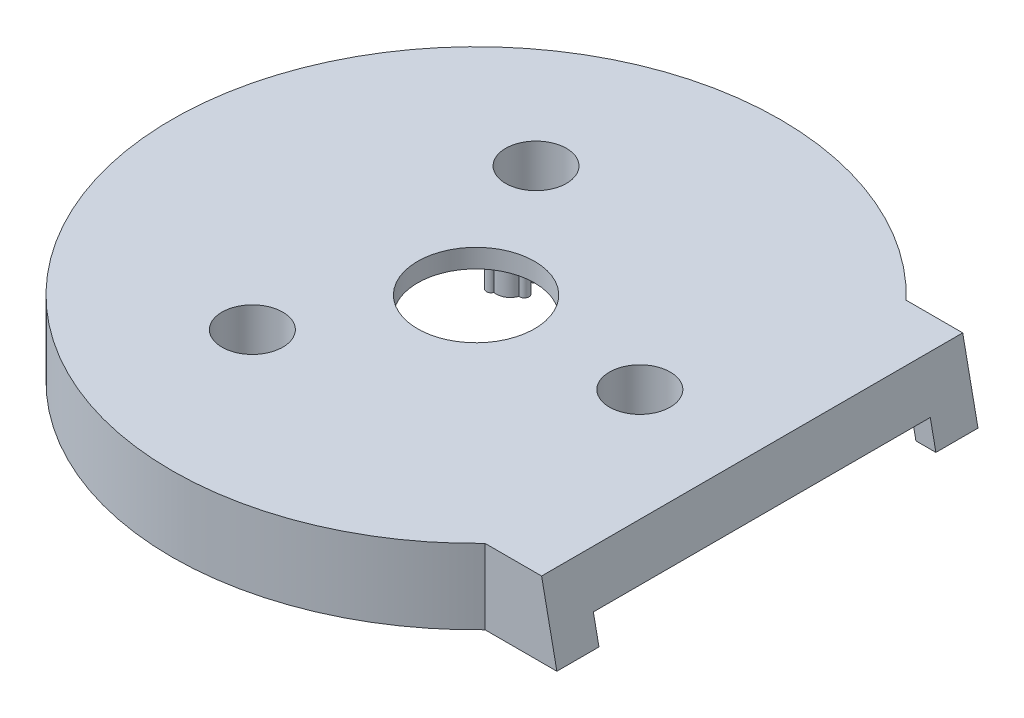
from build123d import *

# Parameters (mm, degrees)
BOSS_EXTRUDE1_DEPTH         = 16
CUT_EXTRUDE1_DEPTH          = 12
SKETCH4_W                   = 72
SKETCH4_H                   = 5
CUT_EXTRUDE2_DEPTH          = 16
SKETCH8_R                   = 3.5
SKETCH8_R_2                 = 1.5
INTERNALHOLESBODY_DEPTH     = 12
SKETCH13_R                  = 1.5
INTERNALHOLESCUT_DEPTH      = 12
SKETCH15_W                  = 14.23560612
SKETCH15_H                  = 16
INTERNALBODYEXTENSION_DEPTH = 90
EXTERNALDIAGONALCUT_DEPTH   = 90
DIAGONALCUT_START           = -4.8
DIAGONALCUT_DEPTH           = 80.4
SKETCH19_W                  = 72
SKETCH19_H                  = 6
DISPLAYCUT_DEPTH            = 8.4
SKETCH26_R                  = 6.5
BOSS_EXTRUDE2_DEPTH         = 11
SKETCH27_R                  = 6.5
CUT_EXTRUDE3_DEPTH          = 5
SKETCH28_R                  = 8
BOSS_EXTRUDE3_DEPTH         = 1
BOSS_EXTRUDE3_DEPTH_BACK    = 2
SKETCH30_R                  = 1.5
CUT_EXTRUDE4_DEPTH          = 3
SKETCH31_R                  = 8
SKETCH31_R_2                = 1.5
BOSS_EXTRUDE4_DEPTH         = 1
BOSS_EXTRUDE4_DEPTH_BACK    = 2
SKETCH32_R                  = 8
SKETCH32_R_2                = 1.5
BOSS_EXTRUDE5_DEPTH         = 1
BOSS_EXTRUDE5_DEPTH_BACK    = 2
SKETCH34_R                  = 1.5
BOSS_EXTRUDE6_DEPTH         = 8
SKETCH33_R                  = 12.5
CUT_EXTRUDE5_DEPTH          = 5
SKETCH35_R                  = 2
BOSS_EXTRUDE7_DEPTH         = 3


with BuildPart() as part:
    # Sketch1 → Boss-Extrude1 (new body)
    with BuildSketch(Plane(origin=(0, 0, 0), x_dir=(1, 0, 0), z_dir=(0, 1, 0))):
        with BuildLine():
            Line((25, -45.0001724), (25, 44.9998276))
            Line((25, 44.9998276), (46.904322999, 44.9998276))
            ThreePointArc((46.904322999, 44.9998276), (-65, 0.000238913), (46.903992196, -45.0001724))
            Line((46.903992196, -45.0001724), (25, -45.0001724))
        make_face()
        with BuildLine():
            Line((46.904322999, 44.9998276), (25, 44.9998276))
            Line((25, 44.9998276), (25, -45.0001724))
            Line((25, -45.0001724), (46.903992196, -45.0001724))
            ThreePointArc((46.903992196, -45.0001724), (60.306548122, -24.251190767), (65, 0))
            ThreePointArc((65, 0), (60.306637259, 24.250969105), (46.904322999, 44.9998276))
        make_face()
        with BuildLine():
            Line((69, 44.9998276), (46.904322999, 44.9998276))
            ThreePointArc((46.904322999, 44.9998276), (60.306637259, 24.250969105), (65, 0))
            ThreePointArc((65, 0), (60.306548122, -24.251190767), (46.903992196, -45.0001724))
            Line((46.903992196, -45.0001724), (69, -45.0001724))
            Line((69, -45.0001724), (69, 44.9998276))
        make_face()
    extrude(amount=BOSS_EXTRUDE1_DEPTH)

    # Sketch3 → Cut-Extrude1 (cut)
    with BuildSketch(Plane.XZ):
        with BuildLine():
            Line((13.648760289, 40.2001724), (44.541510291, 40.2001724))
            ThreePointArc((44.541510291, 40.2001724), (-60, -0.000232232), (44.541821482, -40.1998276))
            Line((44.541821482, -40.1998276), (13.648760289, -40.1998276))
            Line((13.648760289, -40.1998276), (13.648760289, 40.2001724))
        make_face()
        with BuildLine():
            ThreePointArc((60, 0), (56.002190214, 21.53496439), (44.541510291, 40.2001724))
            Line((44.541510291, 40.2001724), (13.648760289, 40.2001724))
            Line((13.648760289, 40.2001724), (13.648760289, -40.1998276))
            Line((13.648760289, -40.1998276), (44.541821482, -40.1998276))
            ThreePointArc((44.541821482, -40.1998276), (56.002273565, -21.534747631), (60, 0))
        make_face()
        with BuildLine():
            Line((64, -40.1998276), (64, 40.2001724))
            Line((64, 40.2001724), (44.541510291, 40.2001724))
            ThreePointArc((44.541510291, 40.2001724), (56.002190214, 21.53496439), (60, 0))
            ThreePointArc((60, 0), (56.002273565, -21.534747631), (44.541821482, -40.1998276))
            Line((44.541821482, -40.1998276), (64, -40.1998276))
        make_face()
    extrude(amount=-CUT_EXTRUDE1_DEPTH, mode=Mode.SUBTRACT)

    # Sketch4 → Cut-Extrude2 (cut)
    with BuildSketch(Plane(origin=(69, 0, 0), x_dir=(0, 0, -1), z_dir=(1, 0, 0))):
        with Locations((-0.0001724, 2.5)):
            Rectangle(SKETCH4_W, SKETCH4_H)
    extrude(amount=-CUT_EXTRUDE2_DEPTH, mode=Mode.SUBTRACT)

    # Sketch8 → InternalHolesBody (add)
    with BuildSketch(Plane.XZ.offset(-12)):
        with Locations((-25.212285918, 54.445758685)):
            Circle(SKETCH8_R)
        with Locations((-25.212285918, 54.445758685)):
            Circle(SKETCH8_R_2, mode=Mode.SUBTRACT)
        with Locations((-25, -54.543560573)):
            Circle(SKETCH8_R)
        with Locations((-25, -54.543560573)):
            Circle(SKETCH8_R_2, mode=Mode.SUBTRACT)
        with Locations((44.541510291, 40.2001724)):
            Circle(SKETCH8_R)
        with Locations((44.541510291, 40.2001724)):
            Circle(SKETCH8_R_2, mode=Mode.SUBTRACT)
        with Locations((44.541821482, -40.1998276)):
            Circle(SKETCH8_R)
        with Locations((44.541821482, -40.1998276)):
            Circle(SKETCH8_R_2, mode=Mode.SUBTRACT)
    extrude(amount=INTERNALHOLESBODY_DEPTH)

    # Sketch13 → InternalHolesCut (cut)
    with BuildSketch(Plane.XZ.offset(-12)):
        with Locations((44.541510291, 40.2001724)):
            Circle(SKETCH13_R)
        with Locations((-25.212285918, 54.445758685)):
            Circle(SKETCH13_R)
        with Locations((-25, -54.543560573)):
            Circle(SKETCH13_R)
        with Locations((44.541821482, -40.1998276)):
            Circle(SKETCH13_R)
    extrude(amount=INTERNALHOLESCUT_DEPTH, mode=Mode.SUBTRACT)

    # Sketch15 → InternalBodyExtension (add)
    with BuildSketch(Plane.XY.offset(45.0001724)):
        with Locations((61.88219694, 8)):
            Rectangle(SKETCH15_W, SKETCH15_H)
    extrude(amount=-INTERNALBODYEXTENSION_DEPTH)

    # Sketch14 → ExternalDiagonalCut (cut)
    with BuildSketch(Plane(origin=(0, 0, -44.9998276), x_dir=(-1, 0, 0), z_dir=(0, 0, -1))):
        Polygon((-69, 16), (-59, 16), (-69, -33), align=None)
    extrude(amount=-EXTERNALDIAGONALCUT_DEPTH, mode=Mode.SUBTRACT)

    # Sketch17 → DiagonalCut (cut)
    with BuildSketch(Plane.XY.offset(45.0001724).offset(DIAGONALCUT_START)):
        Polygon((58.000000002, 0), (54.73469388, 0), (54.73469388, 12), (55.551020411, 12), align=None)
    extrude(amount=-DIAGONALCUT_DEPTH, mode=Mode.SUBTRACT)

    # Sketch19 → DisplayCut (cut)
    with BuildSketch(Plane(origin=(59.775689724, 12.199120352, 0), x_dir=(0, 0, -1), z_dir=(0.979804059, 0.199960012, 0))):
        with Locations((-0.0001724, -9.450571359)):
            Rectangle(SKETCH19_W, SKETCH19_H)
    extrude(amount=-DISPLAYCUT_DEPTH, mode=Mode.SUBTRACT)

    # Sketch26 → Boss-Extrude2 (add)
    with BuildSketch(Plane.XZ.offset(-12)):
        with BuildLine():
            ThreePointArc((-20.136370657, 22.757773897), (-13.5, 23.382685902), (-9.640625, 28.817495477))
            ThreePointArc((-9.640625, 28.817495477), (-8, 30.310889132), (-9.640625, 31.804282788))
            ThreePointArc((-9.640625, 31.804282788), (-13.5, 37.239092363), (-20.136370657, 37.864004368))
            ThreePointArc((-20.136370657, 37.864004368), (-22.25, 38.538130468), (-22.723004343, 36.370610713))
            ThreePointArc((-22.723004343, 36.370610713), (-25.5, 30.310889132), (-22.723004343, 24.251167552))
            ThreePointArc((-22.723004343, 24.251167552), (-22.25, 22.083647797), (-20.136370657, 22.757773897))
        make_face()
        with Locations((-17.5, 30.310889132)):
            Circle(SKETCH26_R, mode=Mode.SUBTRACT)
        with BuildLine():
            ThreePointArc((-22.723004343, -24.251167552), (-25.5, -30.310889132), (-22.723004343, -36.370610713))
            ThreePointArc((-22.723004343, -36.370610713), (-22.25, -38.538130468), (-20.136370657, -37.864004368))
            ThreePointArc((-20.136370657, -37.864004368), (-13.5, -37.239092363), (-9.640625, -31.804282788))
            ThreePointArc((-9.640625, -31.804282788), (-8, -30.310889132), (-9.640625, -28.817495477))
            ThreePointArc((-9.640625, -28.817495477), (-13.5, -23.382685902), (-20.136370657, -22.757773897))
            ThreePointArc((-20.136370657, -22.757773897), (-22.25, -22.083647797), (-22.723004343, -24.251167552))
        make_face()
        with Locations((-17.5, -30.310889132)):
            Circle(SKETCH26_R, mode=Mode.SUBTRACT)
        with BuildLine():
            ThreePointArc((42.859375, 1.493393655), (39, 6.92820323), (32.363629343, 7.553115235))
            ThreePointArc((32.363629343, 7.553115235), (30.25, 8.227241336), (29.776995657, 6.05972158))
            ThreePointArc((29.776995657, 6.05972158), (27, 0), (29.776995657, -6.05972158))
            ThreePointArc((29.776995657, -6.05972158), (30.25, -8.227241336), (32.363629343, -7.553115235))
            ThreePointArc((32.363629343, -7.553115235), (39, -6.92820323), (42.859375, -1.493393655))
            ThreePointArc((42.859375, -1.493393655), (44.5, 0), (42.859375, 1.493393655))
        make_face()
        with Locations((35, 0)):
            Circle(SKETCH26_R, mode=Mode.SUBTRACT)
    extrude(amount=BOSS_EXTRUDE2_DEPTH)

    # Sketch27 → Cut-Extrude3 (cut, through all)
    with BuildSketch(Plane.XZ.offset(-12)):
        with Locations((-17.5, 30.310889132)):
            Circle(SKETCH27_R)
        with Locations((35, 0)):
            Circle(SKETCH27_R)
        with Locations((-17.5, -30.310889132)):
            Circle(SKETCH27_R)
    extrude(amount=-CUT_EXTRUDE3_DEPTH, mode=Mode.SUBTRACT)

    # Sketch28 → Boss-Extrude3 (add, two sides)
    with BuildSketch(Plane.XZ.offset(-1)) as boss_extrude3_sk:
        with Locations((-17.5, 30.310889132)):
            Circle(SKETCH28_R)
    extrude(amount=BOSS_EXTRUDE3_DEPTH)
    extrude(boss_extrude3_sk.sketch, amount=-BOSS_EXTRUDE3_DEPTH_BACK)

    # Sketch30 → Cut-Extrude4 (cut)
    with BuildSketch(Plane.XZ):
        with Locations((-17.5, 30.310889132)):
            Circle(SKETCH30_R)
    extrude(amount=-CUT_EXTRUDE4_DEPTH, mode=Mode.SUBTRACT)

    # Sketch31 → Boss-Extrude4 (add, two sides)
    with BuildSketch(Plane.XZ.offset(-1)) as boss_extrude4_sk:
        with Locations((35, 0)):
            Circle(SKETCH31_R)
        with Locations((35, 0)):
            Circle(SKETCH31_R_2, mode=Mode.SUBTRACT)
    extrude(amount=BOSS_EXTRUDE4_DEPTH)
    extrude(boss_extrude4_sk.sketch, amount=-BOSS_EXTRUDE4_DEPTH_BACK)

    # Sketch32 → Boss-Extrude5 (add, two sides)
    with BuildSketch(Plane.XZ.offset(-1)) as boss_extrude5_sk:
        with Locations((-17.5, -30.310889132)):
            Circle(SKETCH32_R)
        with Locations((-17.5, -30.310889132)):
            Circle(SKETCH32_R_2, mode=Mode.SUBTRACT)
    extrude(amount=BOSS_EXTRUDE5_DEPTH)
    extrude(boss_extrude5_sk.sketch, amount=-BOSS_EXTRUDE5_DEPTH_BACK)

    # Sketch34 → Boss-Extrude6 (add)
    with BuildSketch(Plane.XZ.offset(-12)):
        with BuildLine():
            ThreePointArc((-12.27057923, 19.281240071), (-13, 17.320508076), (-12.27057923, 15.35977608))
            ThreePointArc((-12.27057923, 15.35977608), (-12, 13.856406461), (-10.562754103, 14.373762783))
            ThreePointArc((-10.562754103, 14.373762783), (-8.5, 14.722431864), (-7.166666667, 16.334494779))
            ThreePointArc((-7.166666667, 16.334494779), (-6, 17.320508076), (-7.166666667, 18.306521373))
            ThreePointArc((-7.166666667, 18.306521373), (-8.5, 19.918584287), (-10.562754103, 20.267253368))
            ThreePointArc((-10.562754103, 20.267253368), (-12, 20.784609691), (-12.27057923, 19.281240071))
        make_face()
        with Locations((-10, 17.320508076)):
            Circle(SKETCH34_R, mode=Mode.SUBTRACT)
        with BuildLine():
            ThreePointArc((-12.27057923, -15.35977608), (-13, -17.320508076), (-12.27057923, -19.281240071))
            ThreePointArc((-12.27057923, -19.281240071), (-12, -20.784609691), (-10.562754103, -20.267253368))
            ThreePointArc((-10.562754103, -20.267253368), (-8.5, -19.918584287), (-7.166666667, -18.306521373))
            ThreePointArc((-7.166666667, -18.306521373), (-6, -17.320508076), (-7.166666667, -16.334494779))
            ThreePointArc((-7.166666667, -16.334494779), (-8.5, -14.722431864), (-10.562754103, -14.373762783))
            ThreePointArc((-10.562754103, -14.373762783), (-12, -13.856406461), (-12.27057923, -15.35977608))
        make_face()
        with Locations((-10, -17.320508076)):
            Circle(SKETCH34_R, mode=Mode.SUBTRACT)
        with BuildLine():
            ThreePointArc((17.72942077, 1.960731995), (17, 0), (17.72942077, -1.960731995))
            ThreePointArc((17.72942077, -1.960731995), (18, -3.464101615), (19.437245897, -2.946745293))
            ThreePointArc((19.437245897, -2.946745293), (21.5, -2.598076211), (22.833333333, -0.986013297))
            ThreePointArc((22.833333333, -0.986013297), (24, 0), (22.833333333, 0.986013297))
            ThreePointArc((22.833333333, 0.986013297), (21.5, 2.598076211), (19.437245897, 2.946745293))
            ThreePointArc((19.437245897, 2.946745293), (18, 3.464101615), (17.72942077, 1.960731995))
        make_face()
        with Locations((20, 0)):
            Circle(SKETCH34_R, mode=Mode.SUBTRACT)
    extrude(amount=BOSS_EXTRUDE6_DEPTH)

    # Sketch33 → Cut-Extrude5 (cut, through all)
    with BuildSketch(Plane.XZ.offset(-12)):
        Circle(SKETCH33_R)
    extrude(amount=-CUT_EXTRUDE5_DEPTH, mode=Mode.SUBTRACT)

    # Sketch35 → Boss-Extrude7 (add)
    with BuildSketch(Plane.XZ.offset(-12)):
        with Locations((20, 0)):
            Circle(SKETCH35_R)
        with Locations((-10, -17.320508076)):
            Circle(SKETCH35_R)
        with Locations((-10, 17.320508076)):
            Circle(SKETCH35_R)
    extrude(amount=BOSS_EXTRUDE7_DEPTH)


solid = part.part
